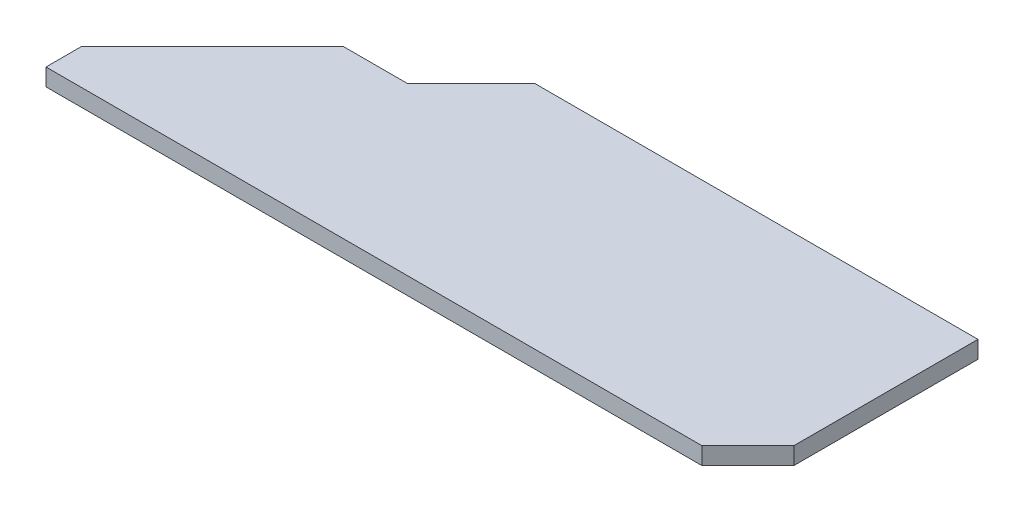
from build123d import *

# Parameters (mm, degrees)
SKETCH1_W           = 114
SKETCH1_H           = 40
BOSS_EXTRUDE1_DEPTH = 3
CUT_EXTRUDE1_DEPTH  = 4
BOSS_EXTRUDE2_DEPTH = 3


with BuildPart() as part:
    # Sketch1 → Boss-Extrude1 (new body)
    with BuildSketch(Plane(origin=(0, 0, 0), x_dir=(1, 0, 0), z_dir=(0, 1, 0))):
        with Locations((-24.485507246, 12.735507246)):
            Rectangle(SKETCH1_W, SKETCH1_H)
    extrude(amount=BOSS_EXTRUDE1_DEPTH)

    # Sketch2 → Cut-Extrude1 (cut, through all)
    with BuildSketch(Plane(origin=(0, 3, 0), x_dir=(1, 0, 0), z_dir=(0, 1, 0))):
        Polygon((-36.485507246, 32.735507246), (-44.165937049, 25.055077444), (-47.560826058, 21.660188435), (-58.747394556, 21.660188435), (-72.532338505, 7.875244486), (-81.485507246, -1.077924256), (-81.485507246, 32.735507246), align=None)
    extrude(amount=-CUT_EXTRUDE1_DEPTH, mode=Mode.SUBTRACT)

    # Sketch3 → Boss-Extrude2 (add, through all)
    with BuildSketch(Plane(origin=(0, 3, 0), x_dir=(1, 0, 0), z_dir=(0, 1, 0))):
        Polygon((32.514492754, -7.264492754), (40.514492754, 0.735507246), (40.514492754, 32.735507246), (32.514492754, 32.735507246), align=None)
    extrude(amount=-BOSS_EXTRUDE2_DEPTH)


solid = part.part
